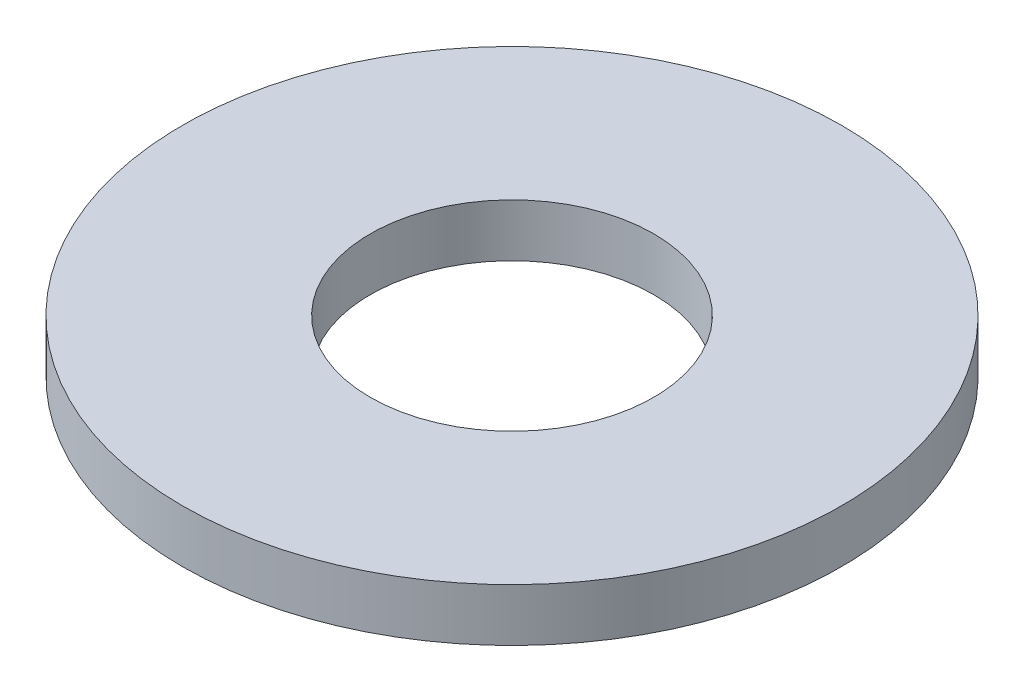
from build123d import *

# Parameters (mm, degrees)
SKETCH2_R           = 5
SKETCH2_R_2         = 2.15
BOSS_EXTRUDE1_DEPTH = 0.8


with BuildPart() as part:
    # Sketch2 → Boss-Extrude1 (new body)
    with BuildSketch(Plane(origin=(0, 0, 0), x_dir=(1, 0, 0), z_dir=(0, 1, 0))):
        Circle(SKETCH2_R)
        Circle(SKETCH2_R_2, mode=Mode.SUBTRACT)
    extrude(amount=BOSS_EXTRUDE1_DEPTH)


solid = part.part
